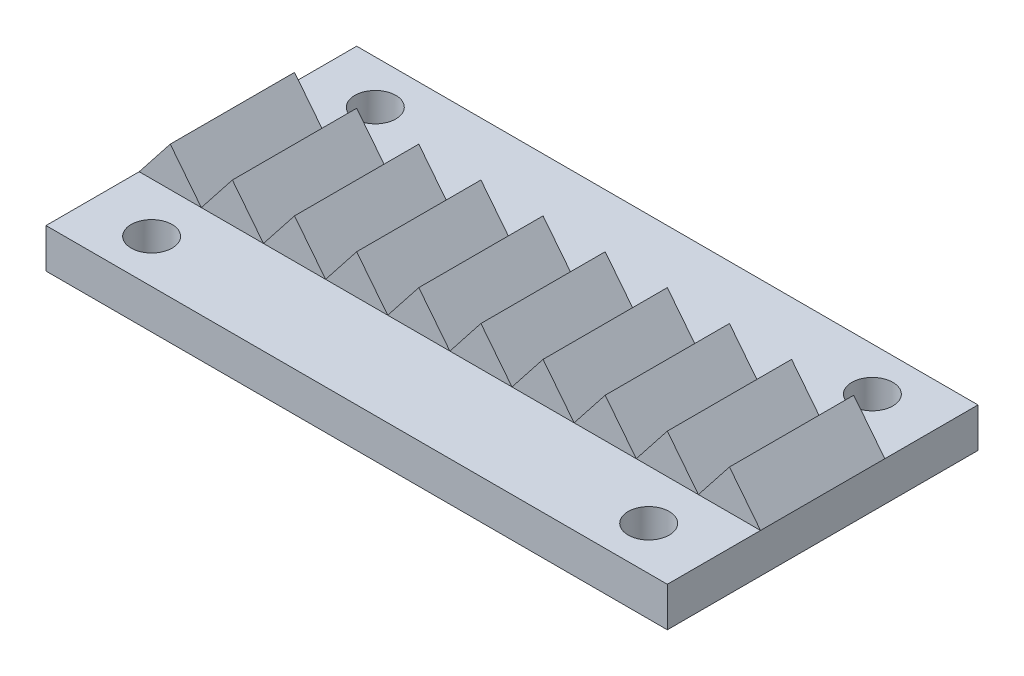
from build123d import *

# Parameters (mm, degrees)
SKETCH1_W                 = 50
SKETCH1_H                 = 25
BOSS_EXTRUDE1_DEPTH       = 3.175
M4X0_7_TAPPED_HOLE1_D     = 3.3
M4X0_7_TAPPED_HOLE1_DEPTH = 10.1
M4X0_7_TAPPED_HOLE1_TIP   = 0.991420021
BOSS_EXTRUDE2_START       = -7.5
BOSS_EXTRUDE2_DEPTH       = 10


with BuildPart() as part:
    # Sketch1 → Boss-Extrude1 (new body)
    with BuildSketch(Plane(origin=(0, 0, 0), x_dir=(1, 0, 0), z_dir=(0, 1, 0))):
        with Locations((25, 12.5)):
            Rectangle(SKETCH1_W, SKETCH1_H)
    extrude(amount=BOSS_EXTRUDE1_DEPTH)

    # M4x0.7 Tapped Hole1
    with Locations(Plane(origin=(5, 3.175, -21.5), x_dir=(0, 0, 1), z_dir=(0, 1, 0))):
        with Locations((0, 0), (0, 40), (18, 0), (18, 40)):
            Hole(M4X0_7_TAPPED_HOLE1_D / 2, depth=M4X0_7_TAPPED_HOLE1_DEPTH)
            with Locations((0, 0, -(M4X0_7_TAPPED_HOLE1_DEPTH + M4X0_7_TAPPED_HOLE1_TIP / 2))):  # 118° drill point
                Cone(0, M4X0_7_TAPPED_HOLE1_D / 2, M4X0_7_TAPPED_HOLE1_TIP, mode=Mode.SUBTRACT)

    # Sketch4 → Boss-Extrude2 (add)
    with BuildSketch(Plane.XY.offset(BOSS_EXTRUDE2_START)):
        Polygon((0, 3.175), (5, 3.175), (2.5, 6.35), align=None)
        Polygon((5, 3.175), (10, 3.175), (7.5, 6.35), align=None)
        Polygon((10, 3.175), (15, 3.175), (12.5, 6.35), align=None)
        Polygon((15, 3.175), (20, 3.175), (17.5, 6.35), align=None)
        Polygon((20, 3.175), (25, 3.175), (22.5, 6.35), align=None)
        Polygon((27.5, 6.35), (25, 3.175), (30, 3.175), align=None)
        Polygon((32.5, 6.35), (30, 3.175), (35, 3.175), align=None)
        Polygon((37.5, 6.35), (35, 3.175), (40, 3.175), align=None)
        Polygon((42.5, 6.35), (40, 3.175), (45, 3.175), align=None)
        Polygon((47.5, 6.35), (45, 3.175), (50, 3.175), align=None)
    extrude(amount=-BOSS_EXTRUDE2_DEPTH)


solid = part.part
